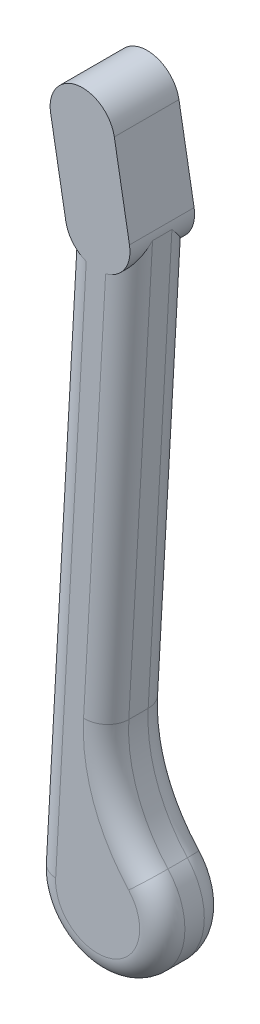
from build123d import *

# Parameters (mm, degrees)
EXTRUDE_1_DEPTH = 20
FILLET_1_R      = 7
EXTRUDE_2_DEPTH = 20


with BuildPart() as part:
    # 草图1 → 凸台-拉伸1 (new body)
    with BuildSketch(Plane.XY):
        with BuildLine():
            Line((-9.984556, 0.555556), (-19.969112, -178.888889))
            ThreePointArc((-19.969112, -178.888889), (6.717955, -198.837969), (14.75992, -166.503898))
            ThreePointArc((14.75992, -166.503898), (5.273091, -150.735791), (2.641696, -132.522913))
            Line((2.641696, -132.522913), (9.984556, -0.555556))
            ThreePointArc((9.984556, -0.555556), (0.555556, 9.984556), (-9.984556, 0.555556))
        make_face()
    extrude(amount=EXTRUDE_1_DEPTH)

    # 圆角1
    fillet_1_edges = [part.edges().sort_by_distance(p)[0] for p in [
        (6.313126, -66.539235, 20),
        (0.555556, 9.984556, 20),
        (-14.976834, -89.166667, 20),
        (6.717955, -198.837969, 20),
        (-14.976834, -89.166667, 0),
        (0.555556, 9.984556, 0),
        (6.313126, -66.539235, 0),
        (5.273091, -150.735791, 0),
        (6.717955, -198.837969, 0),
        (5.273091, -150.735791, 20),
    ]]
    fillet(fillet_1_edges, radius=FILLET_1_R)

    # 草图2 → 凸台-拉伸2 (add)
    with BuildSketch(Plane.XY):
        with BuildLine():
            Line((5.159577, 28.326291), (9.848078, 1.736482))
            ThreePointArc((9.848078, 1.736482), (1.736482, -9.848078), (-9.848078, -1.736482))
            Line((-9.848078, -1.736482), (-14.536578, 24.853328))
            ThreePointArc((-14.536578, 24.853328), (-6.424983, 36.437887), (5.159577, 28.326291))
        make_face()
    extrude(amount=EXTRUDE_2_DEPTH)


solid = part.part
